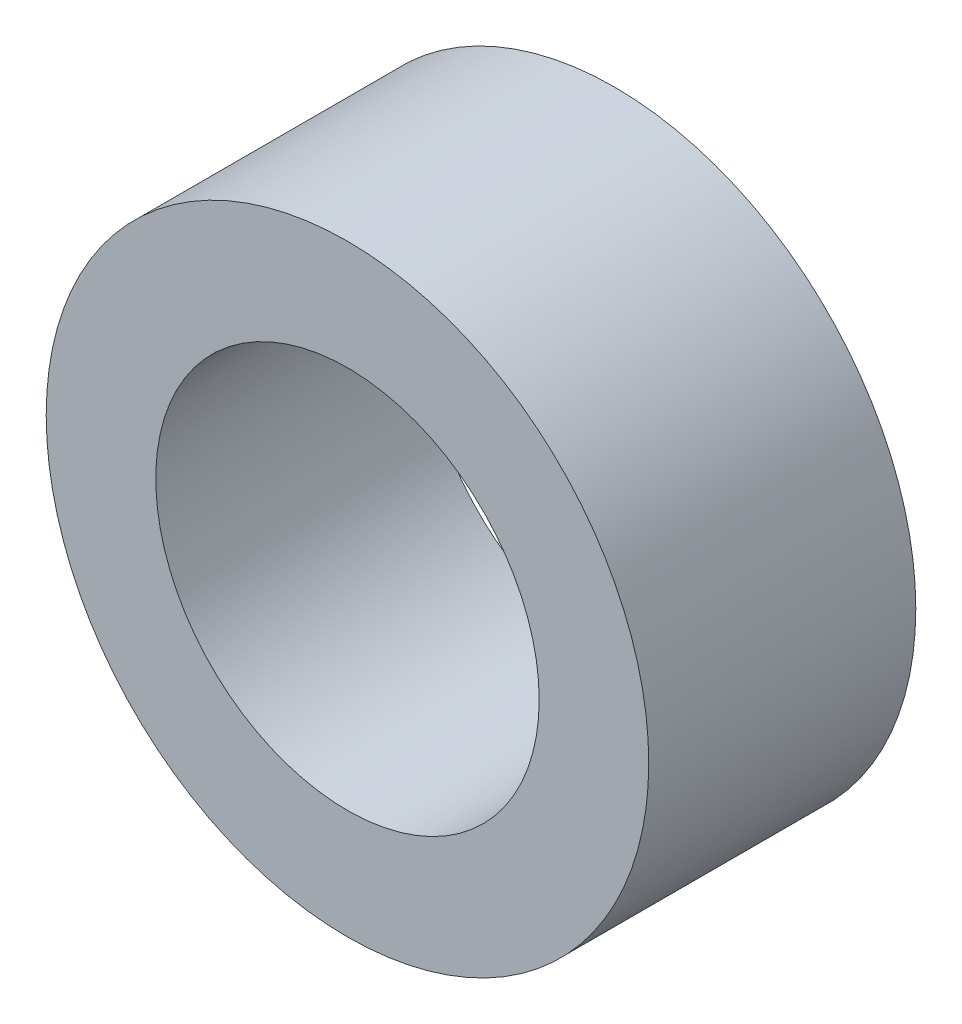
from build123d import *

# Parameters (mm, degrees)
SKETCH1_R           = 44
SKETCH1_R_2         = 28
BOSS_EXTRUDE1_DEPTH = 39


with BuildPart() as part:
    # Sketch1 → Boss-Extrude1 (new body)
    with BuildSketch(Plane.XY):
        Circle(SKETCH1_R)
        Circle(SKETCH1_R_2, mode=Mode.SUBTRACT)
    extrude(amount=BOSS_EXTRUDE1_DEPTH)


solid = part.part
